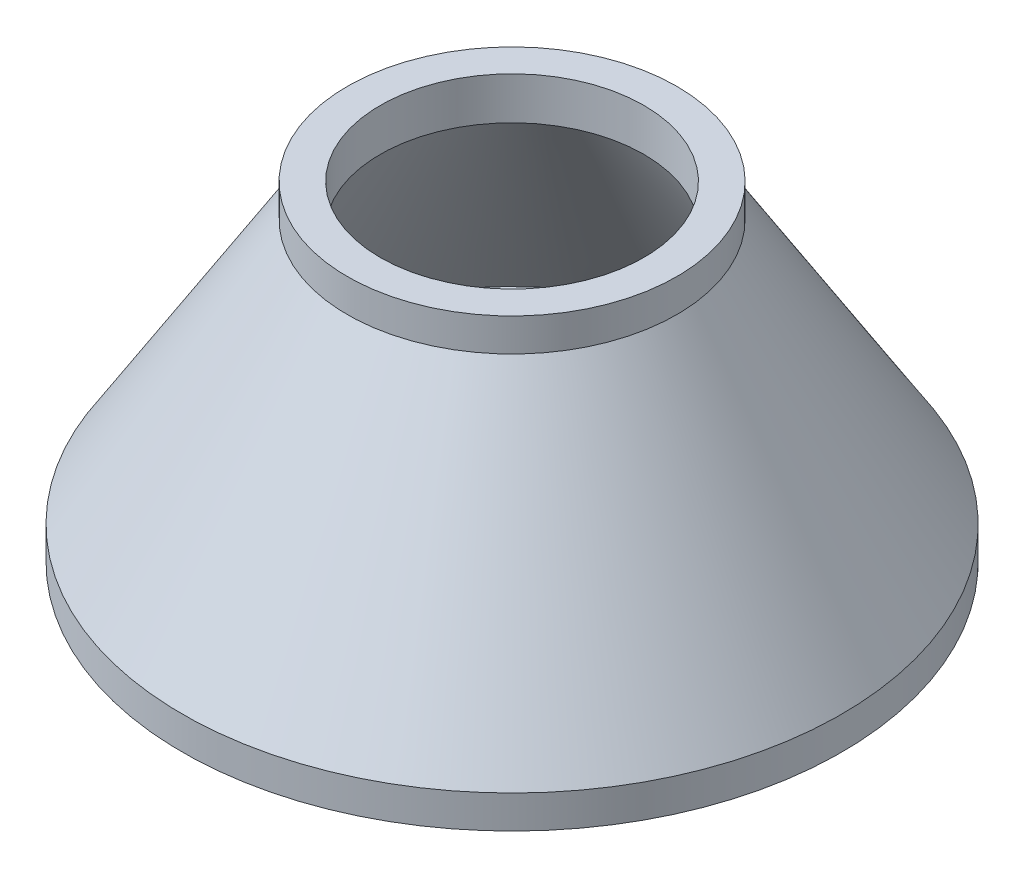
from build123d import *

# Parameters (mm, degrees)
SHELL1_T = -10


with BuildPart() as part:
    # Sketch2 → Revolve1 (revolve)
    with BuildSketch(Plane.XY, mode=Mode.PRIVATE) as revolve1_sk:
        Polygon((0, 0), (100, 0), (100, 10), (50, 90), (50, 100), (0, 100), align=None)
    revolve(revolve1_sk.sketch.rotate(Axis((0, 0, 0), (0, 1, 0)), 90), axis=Axis((0, 0, 0), (0, 1, 0)))

    # Shell1
    shell1_openings = [part.faces().sort_by_distance(p)[0] for p in [
        (0, 100, 0),
    ]]
    offset(amount=SHELL1_T, openings=shell1_openings, kind=Kind.INTERSECTION)


solid = part.part
